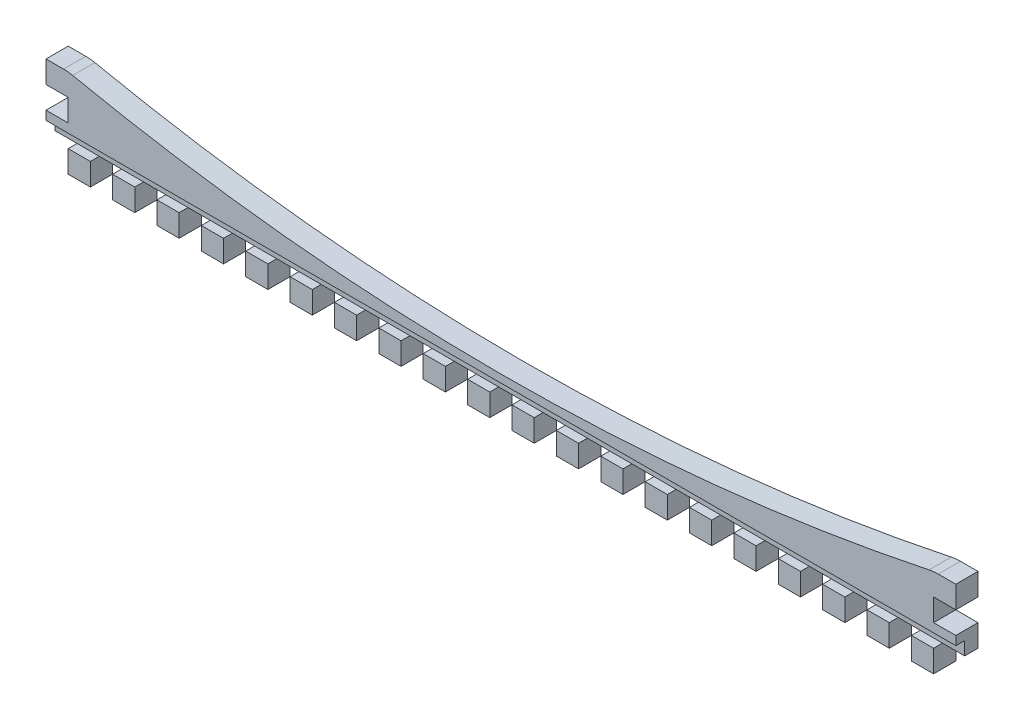
from build123d import *

# Parameters (mm, degrees)
ESQUISSE1_W             = 205
ESQUISSE1_H             = 20
BOSS_EXTRU_1_DEPTH      = 5
ESQUISSE2_W             = 5
ESQUISSE2_H             = 5
ENL_V_MAT_EXTRU_2_DEPTH = 5
ESQUISSE3_W             = 205
ESQUISSE3_H             = 3
ENL_V_MAT_EXTRU_3_DEPTH = 2
CONG_2_R                = 10
CONG_3_R                = 10


with BuildPart() as part:
    # Esquisse1 → Boss.-Extru.1 (new body)
    with BuildSketch(Plane.XY):
        with Locations((56.490511124, -39.453030303)):
            Rectangle(ESQUISSE1_W, ESQUISSE1_H)
    extrude(amount=BOSS_EXTRU_1_DEPTH)

    # Esquisse2 → Enlèv. mat.-Extru.2 (cut)
    with BuildSketch(Plane.XY.offset(5)):
        with Locations((146.490511124, -46.953030303)):
            Rectangle(ESQUISSE2_W, ESQUISSE2_H)
        with Locations((156.490511124, -46.953030303)):
            Rectangle(ESQUISSE2_W, ESQUISSE2_H)
        with Locations((136.490511124, -46.953030303)):
            Rectangle(ESQUISSE2_W, ESQUISSE2_H)
        with Locations((126.490511124, -46.953030303)):
            Rectangle(ESQUISSE2_W, ESQUISSE2_H)
        with Locations((116.490511124, -46.953030303)):
            Rectangle(ESQUISSE2_W, ESQUISSE2_H)
        with Locations((106.490511124, -46.953030303)):
            Rectangle(ESQUISSE2_W, ESQUISSE2_H)
        with Locations((96.490511124, -46.953030303)):
            Rectangle(ESQUISSE2_W, ESQUISSE2_H)
        with Locations((86.490511124, -46.953030303)):
            Rectangle(ESQUISSE2_W, ESQUISSE2_H)
        with Locations((76.490511124, -46.953030303)):
            Rectangle(ESQUISSE2_W, ESQUISSE2_H)
        with Locations((66.490511124, -46.953030303)):
            Rectangle(ESQUISSE2_W, ESQUISSE2_H)
        with Locations((56.490511124, -46.953030303)):
            Rectangle(ESQUISSE2_W, ESQUISSE2_H)
        with Locations((46.490511124, -46.953030303)):
            Rectangle(ESQUISSE2_W, ESQUISSE2_H)
        with Locations((36.490511124, -46.953030303)):
            Rectangle(ESQUISSE2_W, ESQUISSE2_H)
        with Locations((26.490511124, -46.953030303)):
            Rectangle(ESQUISSE2_W, ESQUISSE2_H)
        with Locations((16.490511124, -46.953030303)):
            Rectangle(ESQUISSE2_W, ESQUISSE2_H)
        with Locations((6.490511124, -46.953030303)):
            Rectangle(ESQUISSE2_W, ESQUISSE2_H)
        with Locations((-3.509488876, -46.953030303)):
            Rectangle(ESQUISSE2_W, ESQUISSE2_H)
        with Locations((-13.509488876, -46.953030303)):
            Rectangle(ESQUISSE2_W, ESQUISSE2_H)
        with Locations((-23.509488876, -46.953030303)):
            Rectangle(ESQUISSE2_W, ESQUISSE2_H)
        with Locations((-33.509488876, -46.953030303)):
            Rectangle(ESQUISSE2_W, ESQUISSE2_H)
        with Locations((156.490511124, -36.953030303)):
            Rectangle(ESQUISSE2_W, ESQUISSE2_H)
        with BuildLine():
            Line((-41.009488876, -29.453030303), (153.990511124, -29.453030303))
            ThreePointArc((153.990511124, -29.453030303), (56.490511124, -39.694920166), (-41.009488876, -29.453030303))
        make_face()
        with Locations((-43.509488876, -46.953030303)):
            Rectangle(ESQUISSE2_W, ESQUISSE2_H)
        with Locations((-43.509488876, -36.953030303)):
            Rectangle(ESQUISSE2_W, ESQUISSE2_H)
    extrude(amount=-ENL_V_MAT_EXTRU_2_DEPTH, mode=Mode.SUBTRACT)

    # Esquisse3 → Enlèv. mat.-Extru.3 (cut)
    with BuildSketch(Plane.XY.offset(5)):
        with Locations((56.490511124, -42.953030303)):
            Rectangle(ESQUISSE3_W, ESQUISSE3_H)
    extrude(amount=-ENL_V_MAT_EXTRU_3_DEPTH, mode=Mode.SUBTRACT)

    # Congé2
    cong_2_edges = [part.edges().sort_by_distance(p)[0] for p in [
        (153.990511124, -29.453030303, 2.5),
    ]]
    fillet(cong_2_edges, radius=CONG_2_R)

    # Congé3
    cong_3_edges = [part.edges().sort_by_distance(p)[0] for p in [
        (-41.009488876, -29.453030303, 2.5),
    ]]
    fillet(cong_3_edges, radius=CONG_3_R)


solid = part.part
